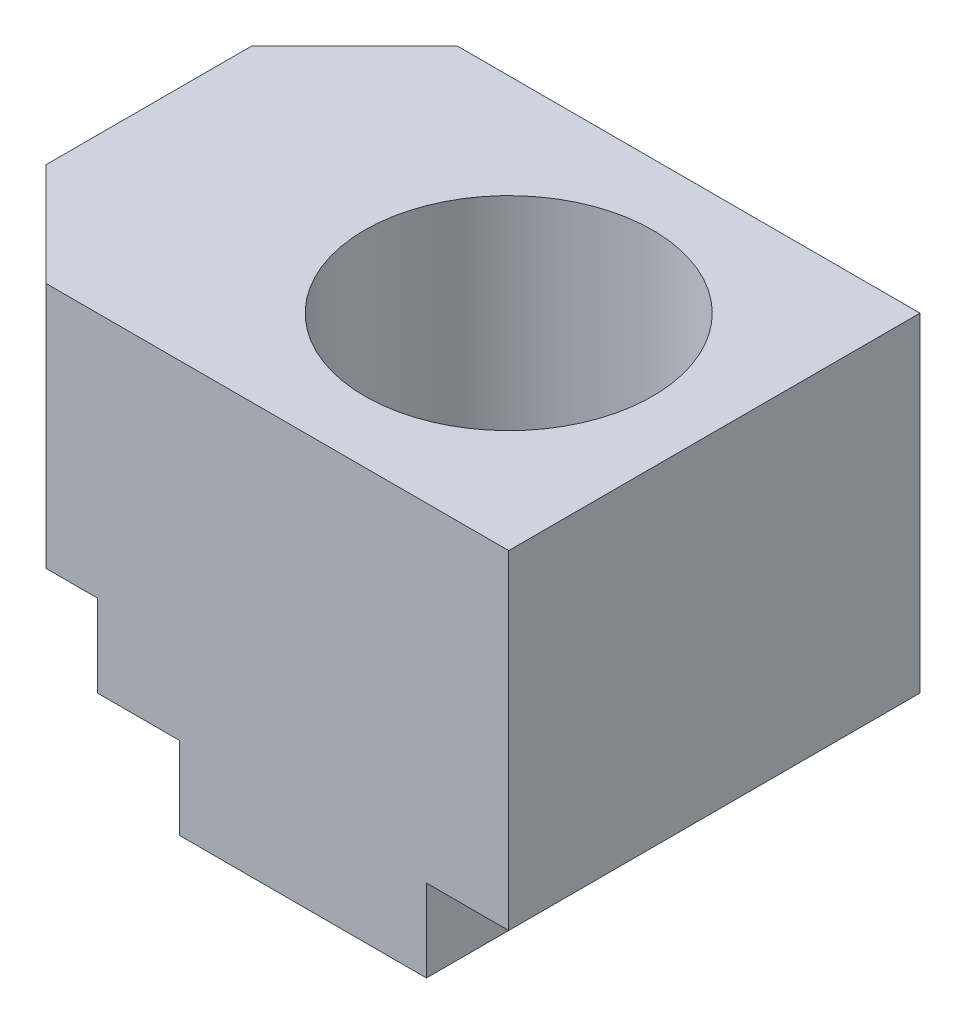
from build123d import *

# Parameters (mm, degrees)
ESQUISSE1_W             = 55
ESQUISSE1_H             = 40
EXTRUSION1_DEPTH        = 40
ESQUISSE2_W             = 8
ESQUISSE2_H             = 8
ENL_V_MAT_EXTRU_1_DEPTH = 41
ENL_V_MAT_EXTRU_2_DEPTH = 40
ENL_V_MAT_EXTRU_3_DEPTH = 40
ENL_V_MAT_EXTRU_4_DEPTH = 40
ESQUISSE6_R             = 8
ENL_V_MAT_EXTRU_5_DEPTH = 41
ESQUISSE7_R             = 14
ENL_V_MAT_EXTRU_6_DEPTH = 20


with BuildPart() as part:
    # Esquisse1 → Extrusion1 (new body)
    with BuildSketch(Plane.XY):
        with Locations((-21.875589067, 0.118096136)):
            Rectangle(ESQUISSE1_W, ESQUISSE1_H)
    extrude(amount=EXTRUSION1_DEPTH)

    # Esquisse2 → Enlèv. mat.-Extru.1 (cut, through all)
    with BuildSketch(Plane.XY.offset(40)):
        with Locations((1.624410933, -15.881903864)):
            Rectangle(ESQUISSE2_W, ESQUISSE2_H)
    extrude(amount=-ENL_V_MAT_EXTRU_1_DEPTH, mode=Mode.SUBTRACT)

    # Esquisse3 → Enlèv. mat.-Extru.2 (cut)
    with BuildSketch(Plane.XY.offset(40)):
        Polygon((-49.375589067, -3.881903864), (-34.375589067, -3.881903864), (-34.375589067, -11.881903864), (-26.375589067, -11.881903864), (-26.375589067, -19.881903864), (-49.375589067, -19.881903864), align=None)
    extrude(amount=-ENL_V_MAT_EXTRU_2_DEPTH, mode=Mode.SUBTRACT)

    # Esquisse4 → Enlèv. mat.-Extru.3 (cut)
    with BuildSketch(Plane(origin=(0, 20.118096136, 0), x_dir=(-1, 0, 0), z_dir=(0, 1, 0))):
        Polygon((49.375589067, 0), (39.375589067, 0), (49.375589067, 10), align=None)
    extrude(amount=-ENL_V_MAT_EXTRU_3_DEPTH, mode=Mode.SUBTRACT)

    # Esquisse5 → Enlèv. mat.-Extru.4 (cut)
    with BuildSketch(Plane(origin=(0, 20.118096136, 0), x_dir=(-1, 0, 0), z_dir=(0, 1, 0))):
        Polygon((49.375589067, 30), (39.375589067, 40), (49.375589067, 40), align=None)
    extrude(amount=-ENL_V_MAT_EXTRU_4_DEPTH, mode=Mode.SUBTRACT)

    # Esquisse6 → Enlèv. mat.-Extru.5 (cut, through all)
    with BuildSketch(Plane(origin=(0, 20.118096136, 0), x_dir=(-1, 0, 0), z_dir=(0, 1, 0))):
        with Locations((14.375589067, 20)):
            Circle(ESQUISSE6_R)
    extrude(amount=-ENL_V_MAT_EXTRU_5_DEPTH, mode=Mode.SUBTRACT)

    # Esquisse7 → Enlèv. mat.-Extru.6 (cut)
    with BuildSketch(Plane(origin=(0, 20.118096136, 0), x_dir=(-1, 0, 0), z_dir=(0, 1, 0))):
        with Locations((14.375589067, 20)):
            Circle(ESQUISSE7_R)
    extrude(amount=-ENL_V_MAT_EXTRU_6_DEPTH, mode=Mode.SUBTRACT)


solid = part.part
